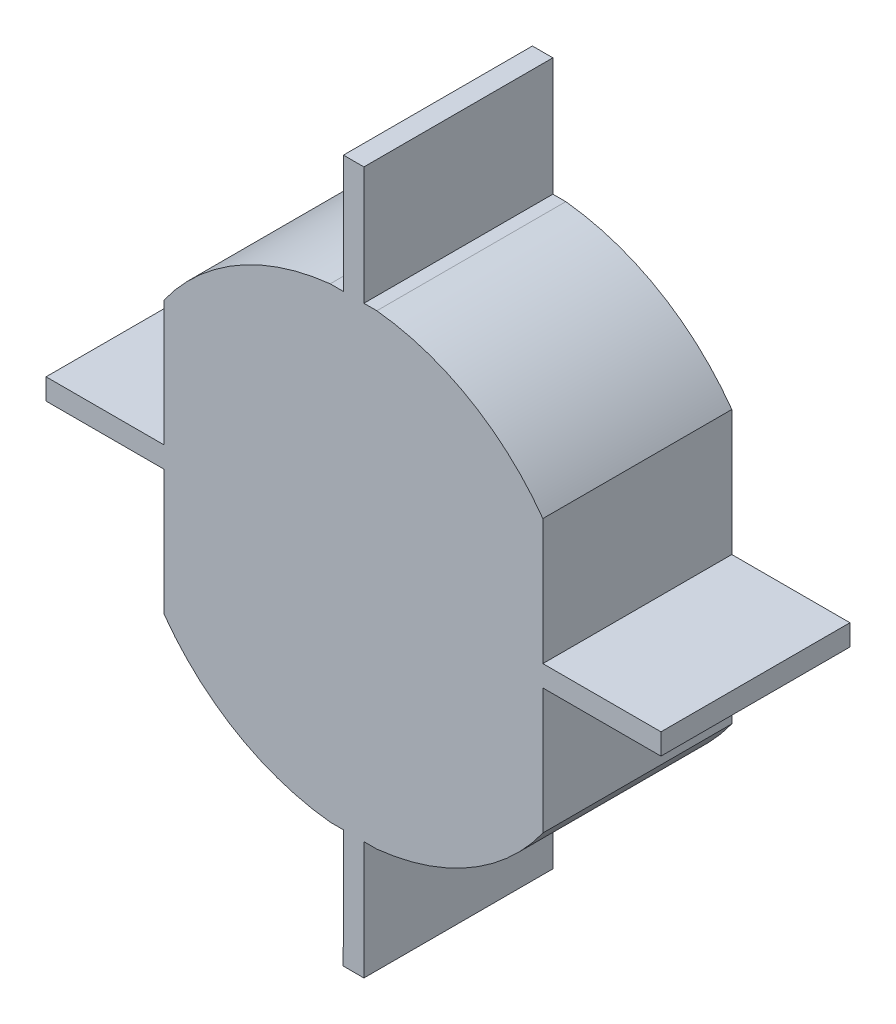
from build123d import *

# Parameters (mm, degrees)
BOSS_EXTRUDE1_DEPTH = 8
CUT_EXTRUDE2_DEPTH  = 9


with BuildPart() as part:
    # Sketch1 → Boss-Extrude1 (new body)
    with BuildSketch(Plane.XY):
        with BuildLine():
            Line((12.878924965, 0.299989593), (12.889991366, 2.998769855))
            Line((12.889991366, 2.998769855), (12.889991366, 3.3))
            Line((12.889991366, 3.3), (12.589993889, 3.3))
            Line((12.589993889, 3.3), (12.227716247, 3.3))
            ThreePointArc((12.227716247, 3.3), (7.127300009, 5.014869597), (3.3, 8.797302437))
            Line((3.3, 8.797302437), (3.3, 14.423444914))
            Line((3.3, 14.423444914), (3.3, 14.723444914))
            Line((3.3, 14.723444914), (3, 14.723444914))
            Line((3, 14.723444914), (0.3, 14.723444914))
            Line((0.3, 14.723444914), (0.3, 15.615227729))
            Line((0.3, 15.615227729), (3, 15.615227729))
            Line((3, 15.615227729), (3.3, 15.615227729))
            Line((3.3, 15.615227729), (3.3, 15.915227729))
            Line((3.3, 15.915227729), (3.3, 21.541370205))
            ThreePointArc((3.3, 21.541370205), (7.127300009, 25.323803045), (12.227716247, 27.038672642))
            Line((12.227716247, 27.038672642), (12.589994095, 27.038672642))
            Line((12.589994095, 27.038672642), (12.889991573, 27.038672642))
            Line((12.889991573, 27.038672642), (12.889991573, 27.339902808))
            Line((12.889991573, 27.339902808), (12.889991573, 30.038672936))
            Line((12.889991573, 30.038672936), (13.756179426, 30.038672936))
            Line((13.756179426, 30.038672936), (13.756179426, 27.338672642))
            Line((13.756179426, 27.338672642), (13.756179426, 27.038672642))
            Line((13.756179426, 27.038672642), (14.056179426, 27.038672642))
            Line((14.056179426, 27.038672642), (14.40506038, 27.038672642))
            ThreePointArc((14.40506038, 27.038672642), (19.505476619, 25.323803045), (23.332776628, 21.541370205))
            Line((23.332776628, 21.541370205), (23.332776628, 15.915227729))
            Line((23.332776628, 15.915227729), (23.332776628, 15.615227729))
            Line((23.332776628, 15.615227729), (23.632776628, 15.615227729))
            Line((23.632776628, 15.615227729), (26.333196522, 15.615227729))
            Line((26.333196522, 15.615227729), (26.333196522, 14.723444914))
            Line((26.333196522, 14.723444914), (23.633196522, 14.723444914))
            Line((23.633196522, 14.723444914), (23.333196522, 14.723444914))
            Line((23.333196522, 14.723444914), (23.333196522, 14.423444914))
            Line((23.333196522, 14.423444914), (23.333196522, 8.797302437))
            ThreePointArc((23.333196522, 8.797302437), (19.505896514, 5.014869597), (14.405480275, 3.3))
            Line((14.405480275, 3.3), (14.056599321, 3.3))
            Line((14.056599321, 3.3), (13.756599321, 3.3))
            Line((13.756599321, 3.3), (13.756599321, 3))
            Line((13.756599321, 3), (13.756599321, 0.3))
            Line((13.756599321, 0.3), (12.878924965, 0.299989593))
        make_face()
    extrude(amount=BOSS_EXTRUDE1_DEPTH)

    # Sketch2 → Cut-Extrude2 (cut, through all)
    with BuildSketch(Plane.XY.offset(8)):
        with BuildLine():
            Line((12.889991573, 30.038672936), (-3.324020912, 25.076549212))
            Line((-3.324020912, 25.076549212), (0.3, 15.615227729))
            Line((0.3, 15.615227729), (3.3, 15.615227729))
            Line((3.3, 15.615227729), (3.3, 21.541370205))
            ThreePointArc((3.3, 21.541370205), (7.127300009, 25.323803045), (12.227716247, 27.038672642))
            Line((12.227716247, 27.038672642), (12.889991573, 27.038672642))
            Line((12.889991573, 27.038672642), (12.889991573, 30.038672936))
        make_face()
        with BuildLine():
            Line((26.333196522, 15.615227729), (25.678702072, 25.392177395))
            Line((25.678702072, 25.392177395), (13.756179426, 30.038672936))
            Line((13.756179426, 30.038672936), (13.756179426, 27.038672642))
            Line((13.756179426, 27.038672642), (14.40506038, 27.038672642))
            ThreePointArc((14.40506038, 27.038672642), (19.505476619, 25.323803045), (23.332776628, 21.541370205))
            Line((23.332776628, 21.541370205), (23.332776628, 15.615227729))
            Line((23.332776628, 15.615227729), (26.333196522, 15.615227729))
        make_face()
        with BuildLine():
            Line((21.332776628, 20.933212865), (21.332776628, 15.615227729))
            Line((21.332776628, 15.615227729), (23.332776628, 15.615227729))
            Line((23.332776628, 15.615227729), (23.332776628, 21.541370205))
            ThreePointArc((23.332776628, 21.541370205), (19.505476619, 25.323803045), (14.40506038, 27.038672642))
            Line((14.40506038, 27.038672642), (13.756179426, 27.038672642))
            Line((13.756179426, 27.038672642), (13.756179426, 25.038672642))
            Line((13.756179426, 25.038672642), (14.303761373, 25.038672642))
            ThreePointArc((14.303761373, 25.038672642), (18.258523966, 23.739709455), (21.332776628, 20.933212865))
        make_face()
        with BuildLine():
            Line((12.329015255, 25.038672642), (12.889991573, 25.038672642))
            Line((12.889991573, 25.038672642), (12.889991573, 27.038672642))
            Line((12.889991573, 27.038672642), (12.227716247, 27.038672642))
            ThreePointArc((12.227716247, 27.038672642), (7.127300009, 25.323803045), (3.3, 21.541370205))
            Line((3.3, 21.541370205), (3.3, 15.615227729))
            Line((3.3, 15.615227729), (5.3, 15.615227729))
            Line((5.3, 15.615227729), (5.3, 20.933212865))
            ThreePointArc((5.3, 20.933212865), (8.374252661, 23.739709455), (12.329015255, 25.038672642))
        make_face()
        with BuildLine():
            Line((5.3, 9.405459777), (5.3, 14.723444914))
            Line((5.3, 14.723444914), (3.3, 14.723444914))
            Line((3.3, 14.723444914), (3.3, 8.797302437))
            ThreePointArc((3.3, 8.797302437), (7.127300009, 5.014869597), (12.227716247, 3.3))
            Line((12.227716247, 3.3), (12.884961194, 3.3))
            Line((12.884961194, 3.3), (12.888985332, 5.3))
            Line((12.888985332, 5.3), (12.329015255, 5.3))
            ThreePointArc((12.329015255, 5.3), (8.374252661, 6.598963188), (5.3, 9.405459777))
        make_face()
        with BuildLine():
            Line((3.3, 8.797302437), (3.3, 14.723444914))
            Line((3.3, 14.723444914), (0.3, 14.723444914))
            Line((0.3, 14.723444914), (4.782985331, 0.07504351))
            Line((4.782985331, 0.07504351), (12.878924965, 0.299989593))
            Line((12.878924965, 0.299989593), (12.884961194, 3.3))
            Line((12.884961194, 3.3), (12.227716247, 3.3))
            ThreePointArc((12.227716247, 3.3), (7.127300009, 5.014869597), (3.3, 8.797302437))
        make_face()
        with BuildLine():
            Line((13.756599321, 5.3), (13.756599321, 3.3))
            Line((13.756599321, 3.3), (14.405480275, 3.3))
            ThreePointArc((14.405480275, 3.3), (19.505896514, 5.014869597), (23.333196522, 8.797302437))
            Line((23.333196522, 8.797302437), (23.333196522, 14.723444914))
            Line((23.333196522, 14.723444914), (21.333196522, 14.723444914))
            Line((21.333196522, 14.723444914), (21.333196522, 9.405459777))
            ThreePointArc((21.333196522, 9.405459777), (18.258943861, 6.598963188), (14.304181268, 5.3))
            Line((14.304181268, 5.3), (13.756599321, 5.3))
        make_face()
        with BuildLine():
            Line((13.756599321, 0.3), (29.080472483, 10.031605851))
            Line((29.080472483, 10.031605851), (26.333196522, 14.723444914))
            Line((26.333196522, 14.723444914), (23.333196522, 14.723444914))
            Line((23.333196522, 14.723444914), (23.333196522, 8.797302437))
            ThreePointArc((23.333196522, 8.797302437), (19.505896514, 5.014869597), (14.405480275, 3.3))
            Line((14.405480275, 3.3), (13.756599321, 3.3))
            Line((13.756599321, 3.3), (13.756599321, 0.3))
        make_face()
    extrude(amount=-CUT_EXTRUDE2_DEPTH, mode=Mode.SUBTRACT)


solid = part.part
